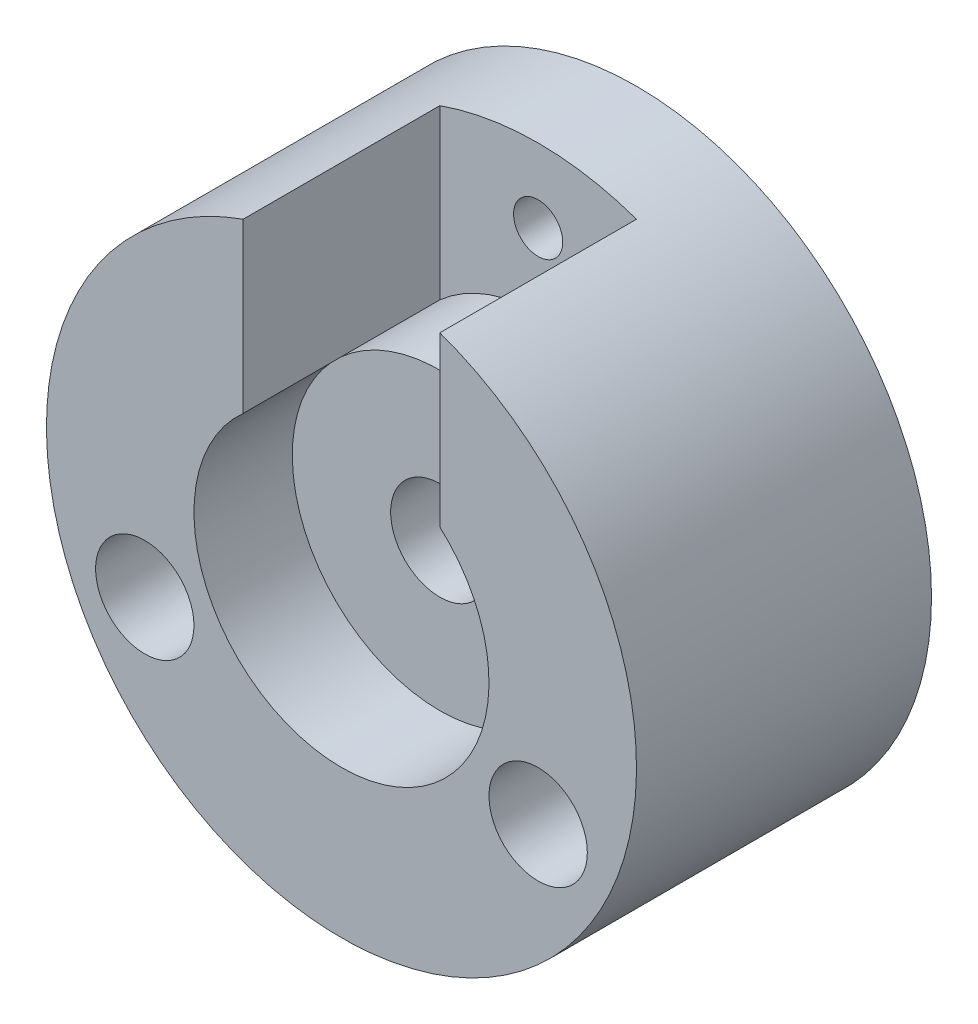
from build123d import *

# Parameters (mm, degrees)
SKETCH1_R           = 30
BOSS_EXTRUDE1_DEPTH = 30
SKETCH2_R           = 15
CUT_EXTRUDE1_DEPTH  = 10
SKETCH3_R           = 5
CUT_EXTRUDE2_DEPTH  = 10
SKETCH5_R           = 5
CUT_EXTRUDE5_DEPTH  = 110
CUT_EXTRUDE6_DEPTH  = 20
SKETCH7_R           = 2.5
CUT_EXTRUDE7_DEPTH  = 20
SKETCH8_R           = 5
CUT_EXTRUDE8_DEPTH  = 10
SKETCH9_R           = 10
CUT_EXTRUDE9_DEPTH  = 10


with BuildPart() as part:
    # Sketch1 → Boss-Extrude1 (new body)
    with BuildSketch(Plane.XY):
        Circle(SKETCH1_R)
    extrude(amount=BOSS_EXTRUDE1_DEPTH)

    # Sketch2 → Cut-Extrude1 (cut)
    with BuildSketch(Plane.XY.offset(30)):
        Circle(SKETCH2_R)
    extrude(amount=-CUT_EXTRUDE1_DEPTH, mode=Mode.SUBTRACT)

    # Sketch3 → Cut-Extrude2 (cut)
    with BuildSketch(Plane.XY.offset(20)):
        Circle(SKETCH3_R)
    extrude(amount=-CUT_EXTRUDE2_DEPTH, mode=Mode.SUBTRACT)

    # Sketch5 → Cut-Extrude5 (cut)
    with BuildSketch(Plane.XY.offset(30)):
        with Locations((20, -10)):
            Circle(SKETCH5_R)
        with Locations((-20, -10)):
            Circle(SKETCH5_R)
    extrude(amount=-CUT_EXTRUDE5_DEPTH, mode=Mode.SUBTRACT)

    # Sketch6 → Cut-Extrude6 (cut)
    with BuildSketch(Plane.XY.offset(30)):
        with BuildLine():
            Line((-10, 28.284271247), (-10, 11.180339887))
            ThreePointArc((-10, 11.180339887), (0, 15), (10, 11.180339887))
            Line((10, 11.180339887), (10, 28.284271247))
            ThreePointArc((10, 28.284271247), (0, 30), (-10, 28.284271247))
        make_face()
    extrude(amount=-CUT_EXTRUDE6_DEPTH, mode=Mode.SUBTRACT)

    # Sketch7 → Cut-Extrude7 (cut)
    with BuildSketch(Plane.XY.offset(10)):
        with Locations((0, 22.5)):
            Circle(SKETCH7_R)
    extrude(amount=-CUT_EXTRUDE7_DEPTH, mode=Mode.SUBTRACT)

    # Sketch8 → Cut-Extrude8 (cut)
    with BuildSketch(Plane.XY.offset(10)):
        Circle(SKETCH8_R)
    extrude(amount=-CUT_EXTRUDE8_DEPTH, mode=Mode.SUBTRACT)

    # Sketch9 → Cut-Extrude9 (cut)
    with BuildSketch(Plane(origin=(0, 0, 0), x_dir=(-1, 0, 0), z_dir=(0, 0, -1))):
        Circle(SKETCH9_R)
    extrude(amount=-CUT_EXTRUDE9_DEPTH, mode=Mode.SUBTRACT)


solid = part.part
